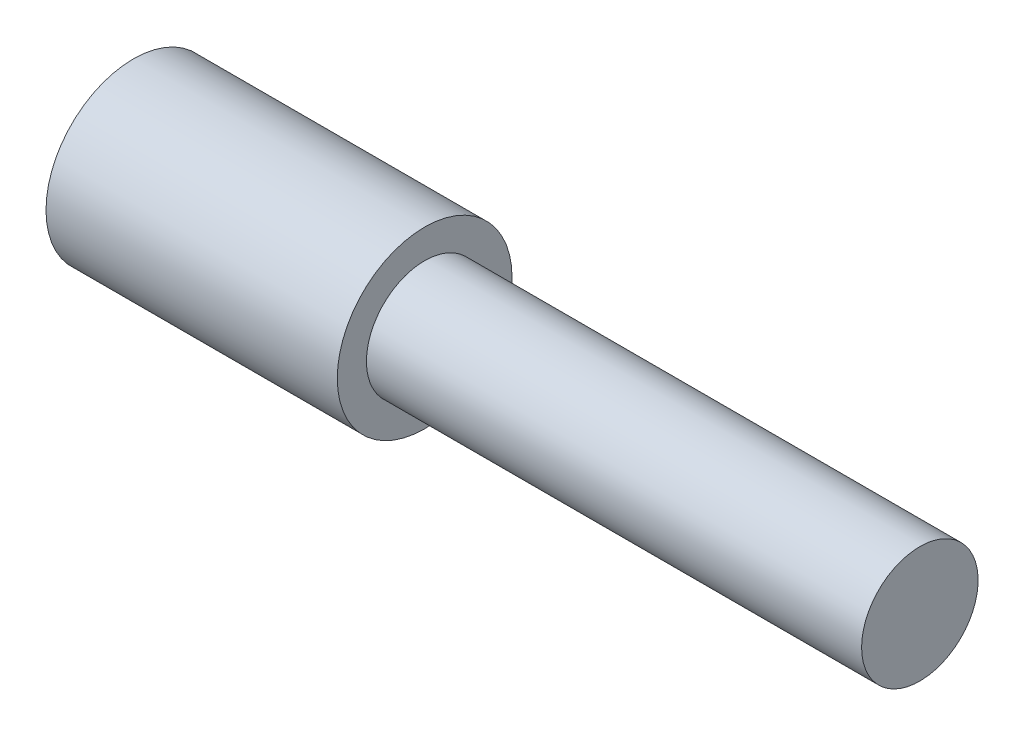
from build123d import *


with BuildPart() as part:
    # Esquisse1 → Révolution1 (revolve)
    with BuildSketch(Plane.XY):
        Polygon((27, 0), (27, 2), (10, 2), (10, 3), (0, 3), (0, 0), align=None)
    revolve(axis=Axis((0, 0, 0), (1, 0, 0)))


solid = part.part
